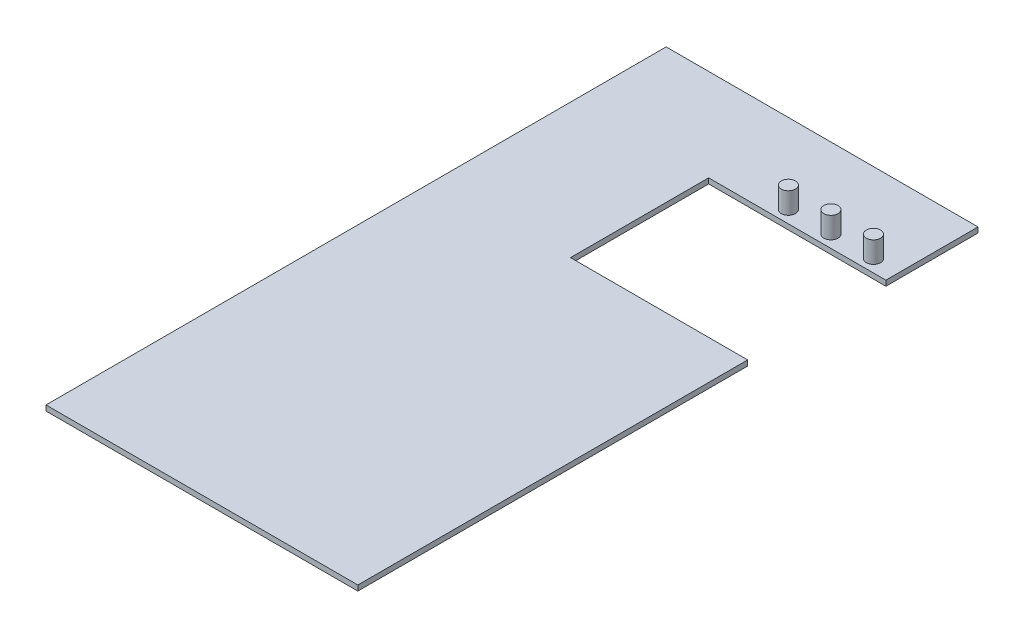
from build123d import *

# Parameters (mm, degrees)
SKETCH1_W           = 88
SKETCH1_H           = 175
BOSS_EXTRUDE1_DEPTH = 1.5
SKETCH2_W           = 50
SKETCH2_H           = 39
CUT_EXTRUDE1_DEPTH  = 1.5
SKETCH3_R           = 2
BOSS_EXTRUDE2_DEPTH = 6


with BuildPart() as part:
    # Sketch1 → Boss-Extrude1 (new body)
    with BuildSketch(Plane(origin=(0, 0, 0), x_dir=(1, 0, 0), z_dir=(0, 1, 0))):
        Rectangle(SKETCH1_W, SKETCH1_H)
    extrude(amount=BOSS_EXTRUDE1_DEPTH)

    # Sketch2 → Cut-Extrude1 (cut)
    with BuildSketch(Plane(origin=(0, 1.5, 0), x_dir=(1, 0, 0), z_dir=(0, 1, 0))):
        with Locations((19, 42)):
            Rectangle(SKETCH2_W, SKETCH2_H)
    extrude(amount=-CUT_EXTRUDE1_DEPTH, mode=Mode.SUBTRACT)

    # Sketch3 → Boss-Extrude2 (add)
    with BuildSketch(Plane(origin=(0, 1.5, 0), x_dir=(1, 0, 0), z_dir=(0, 1, 0))):
        with Locations((37, 65)):
            Circle(SKETCH3_R)
        with Locations((25, 65)):
            Circle(SKETCH3_R)
        with Locations((13, 65)):
            Circle(SKETCH3_R)
    extrude(amount=BOSS_EXTRUDE2_DEPTH)


solid = part.part
